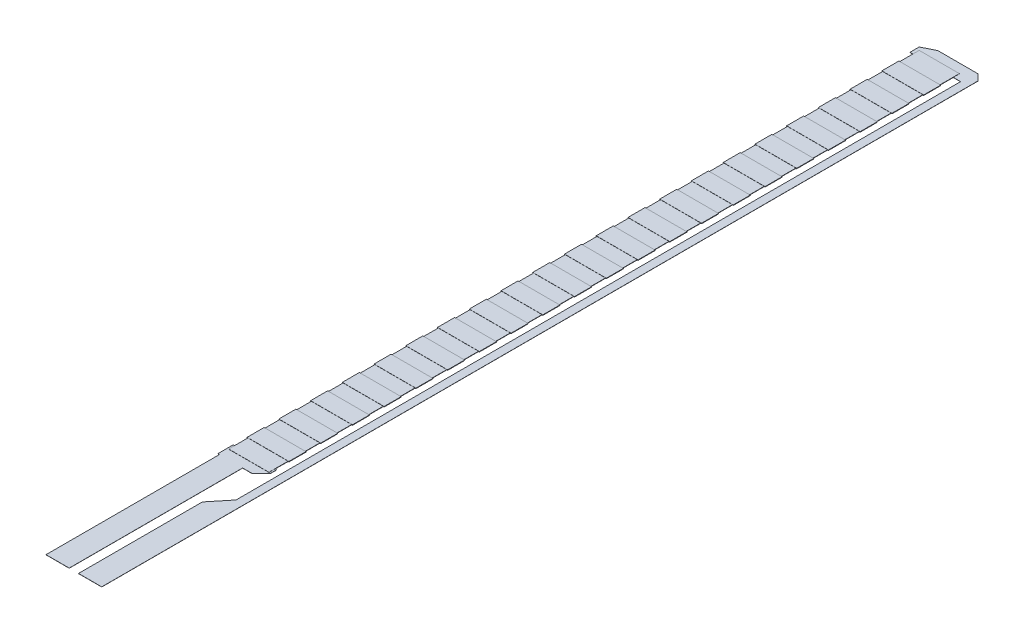
from build123d import *

# Parameters (mm, degrees)
BOSS_EXTRUDE1_DEPTH   = 0.0127
BOSS_EXTRUDE1_2_DEPTH = 0.0127
SKETCH2_W             = 3.302
SKETCH2_H             = 56.642
BOSS_EXTRUDE2_DEPTH   = 0.0254
SKETCH3_W             = 3.429
SKETCH3_H             = 1.397
BOSS_EXTRUDE3_DEPTH   = 0.0381
LPATTERN1_COUNT       = 21
LPATTERN1_PITCH       = 2.6035


with BuildPart() as part:
    # Sketch1 → Boss-Extrude1 (new body)
    with BuildSketch(Plane(origin=(0, 13.025569655, 0), x_dir=(1, 0, 0), z_dir=(0, 1, 0))):
        Polygon((-49.105346889, -54.280248144), (-47.200346889, -54.280248144), (-47.200346889, -44.120248144), (-47.200346889, -42.596248144), (-47.200346889, 16.839751856), (-47.200346889, 17.601751856), (-47.708346889, 18.109751856), (-51.010346889, 18.109751856), (-52.026346889, 17.601751856), (-52.026346889, 16.839751856), (-47.864580691, 16.839751856), (-47.864580691, -42.596248144), (-49.105346889, -44.120248144), align=None)
    extrude(amount=BOSS_EXTRUDE1_DEPTH)



with BuildPart() as body_2:
    # Sketch1 → Boss-Extrude1 2 (new body)
    with BuildSketch(Plane(origin=(0, 13.025569655, 0), x_dir=(1, 0, 0), z_dir=(0, 1, 0))):
        Polygon((-49.867346889, -40.056248144), (-49.105346889, -40.056248144), (-48.343346889, -39.294248144), (-48.343346889, -38.786248144), (-51.899346889, -38.786248144), (-51.899346889, -40.056248144), (-51.772346889, -40.056248144), (-51.772346889, -54.280248144), (-49.867346889, -54.280248144), align=None)
    extrude(amount=BOSS_EXTRUDE1_2_DEPTH)


with BuildPart() as part_1:
    add(part.part)

    add(body_2.part)  # Boss-Extrude2 merges body 2
    # Sketch2 → Boss-Extrude2 (add)
    with BuildSketch(Plane(origin=(0, 13.025569655, 0), x_dir=(1, 0, 0), z_dir=(0, 1, 0))):
        with Locations((-50.121346889, -10.973248144)):
            Rectangle(SKETCH2_W, SKETCH2_H)
    extrude(amount=BOSS_EXTRUDE2_DEPTH)

    # Sketch3 → Boss-Extrude3 (add)
    with BuildSketch(Plane(origin=(0, 13.025569655, 0), x_dir=(1, 0, 0), z_dir=(0, 1, 0))):
        with Locations((-50.121346889, -37.020948144)):
            Rectangle(SKETCH3_W, SKETCH3_H)
    boss_extrude3 = extrude(amount=BOSS_EXTRUDE3_DEPTH)

    # LPattern1: Boss-Extrude3 ×21
    with Locations(*[(0, 0, -i * LPATTERN1_PITCH) for i in range(1, LPATTERN1_COUNT)]):
        add(boss_extrude3)


solid = part_1.part
